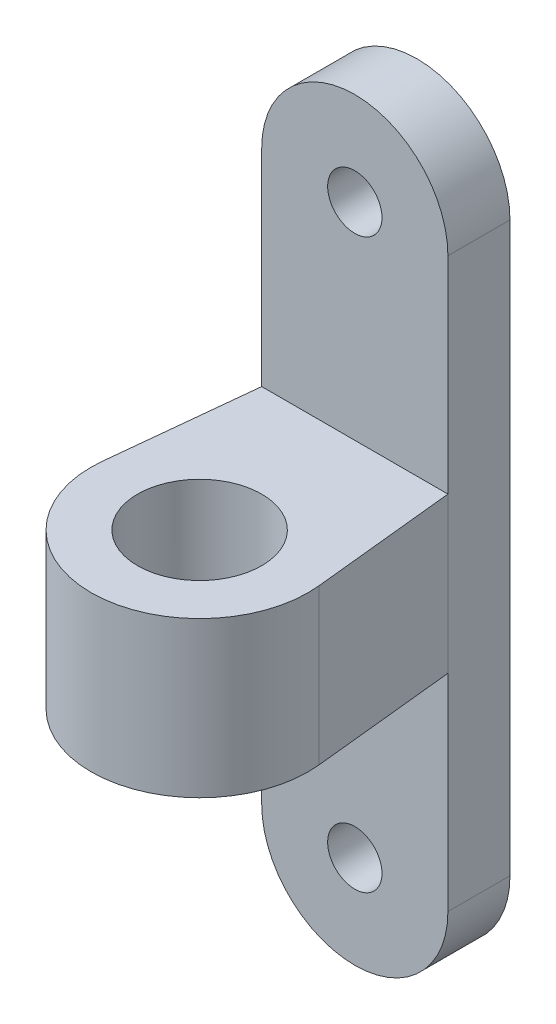
from build123d import *

# Parameters (mm, degrees)
ESBO_O1_R                = 1.75
RESSALTO_EXTRUS_O1_DEPTH = 4
ESBO_O2_W                = 32.967162932
ESBO_O2_H                = 10
RESSALTO_EXTRUS_O2_DEPTH = 25
ESBO_O3_R                = 4
CORTE_EXTRUS_O3_DEPTH    = 42.895088709


with BuildPart() as part:
    # Esboço1 → Ressalto-extrusão1 (new body)
    with BuildSketch(Plane.XY):
        with BuildLine():
            Line((-6, 0), (-6, 36.6))
            ThreePointArc((-6, 36.6), (0, 42.6), (6, 36.6))
            Line((6, 36.6), (6, 0))
            ThreePointArc((6, 0), (0, -6), (-6, 0))
        make_face()
        Circle(ESBO_O1_R, mode=Mode.SUBTRACT)
        with Locations((0, 36.6)):
            Circle(ESBO_O1_R, mode=Mode.SUBTRACT)
    extrude(amount=RESSALTO_EXTRUS_O1_DEPTH)

    # Esboço2 → Ressalto-extrusão2 (add)
    with BuildSketch(Plane(origin=(0, 0, 0), x_dir=(-1, 0, 0), z_dir=(0, 0, -1))):
        with Locations((0, 18.3)):
            Rectangle(ESBO_O2_W, ESBO_O2_H)
    extrude(amount=-RESSALTO_EXTRUS_O2_DEPTH)

    # Esboço3 → Corte-extrusão3 (cut, through all)
    with BuildSketch(Plane(origin=(0, 23.3, 0), x_dir=(1, 0, 0), z_dir=(0, 1, 0))):
        with BuildLine():
            Line((-6.962621571, -13.277572943), (-6, -4))
            Line((-6, -4), (-6, 0))
            Line((-6, 0), (-16.483581466, 0))
            Line((-16.483581466, 0), (-16.483581466, -25))
            Line((-16.483581466, -25), (16.483581466, -25))
            Line((16.483581466, -25), (16.483581466, 0))
            Line((16.483581466, 0), (6, 0))
            Line((6, 0), (6, -4))
            Line((6, -4), (6.962621571, -13.277572943))
            ThreePointArc((6.962621571, -13.277572943), (0, -21), (-6.962621571, -13.277572943))
        make_face()
        with Locations(Location((0, -14, 0), (0, 0, 270))):
            Circle(ESBO_O3_R)
    extrude(amount=-CORTE_EXTRUS_O3_DEPTH, mode=Mode.SUBTRACT)


solid = part.part
